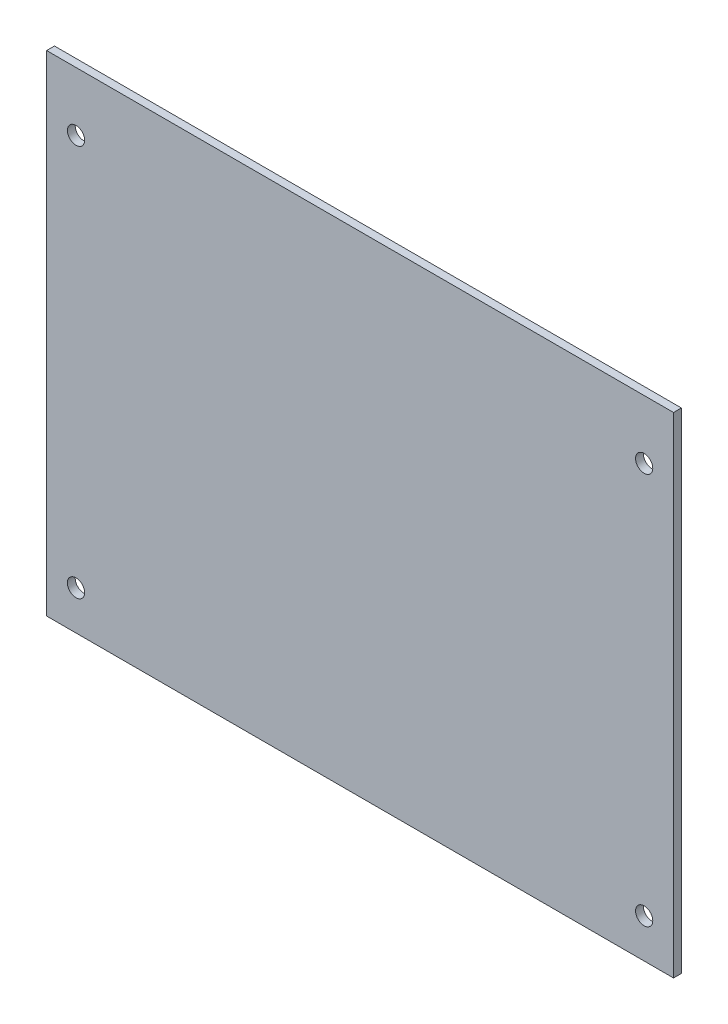
from build123d import *

# Parameters (mm, degrees)
SKETCH_1_W          = 160
SKETCH_1_H          = 125
EXTRUDE_1_DEPTH     = 2
SKETCH_2_R          = 2.2
CUT_EXTRUDE_1_DEPTH = 2


with BuildPart() as part:
    # ｽｹｯﾁ1 → ﾎﾞｽ - 押し出し1 (new body)
    with BuildSketch(Plane.XY):
        Rectangle(SKETCH_1_W, SKETCH_1_H)
    extrude(amount=EXTRUDE_1_DEPTH)

    # ｽｹｯﾁ2 → ｶｯﾄ - 押し出し1 (cut)
    with BuildSketch(Plane.XY.offset(2)):
        with Locations((72.5, -52.5)):
            Circle(SKETCH_2_R)
        with Locations((-72.5, -52.5)):
            Circle(SKETCH_2_R)
        with Locations((-72.5, 47.5)):
            Circle(SKETCH_2_R)
        with Locations((72.5, 47.5)):
            Circle(SKETCH_2_R)
    extrude(amount=-CUT_EXTRUDE_1_DEPTH, mode=Mode.SUBTRACT)


solid = part.part
